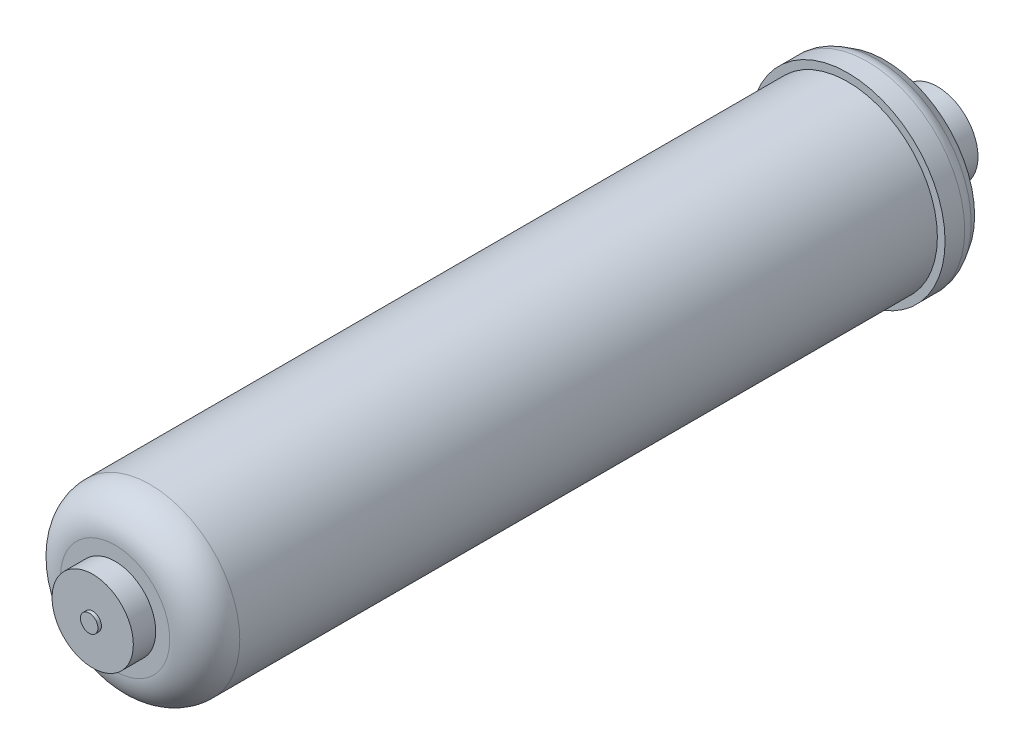
from build123d import *

# Parameters (mm, degrees)
FILLET1_R = 12.7
FILLET2_R = 6.35


with BuildPart() as part:
    # Sketch1 → Revolve1 (revolve)
    with BuildSketch(Plane(origin=(0, 0, 0), x_dir=(0, 0, -1), z_dir=(1, 0, 0))):
        Polygon((0, 0), (0, 3.175), (1.27, 3.175), (1.27, 14.732), (9.398, 14.732), (9.398, 32.512), (275.082, 32.512), (275.082, 35.306), (283.972, 35.306), (288.544, 32.555084127), (299.466, 14.732), (307.594, 14.732), (307.594, 3.175), (308.864, 3.175), (308.864, 0), align=None)
    revolve(axis=Axis((0, 0, 0), (0, 0, -1)))

    # Fillet1
    fillet1_edges = [part.edges().sort_by_distance(p)[0] for p in [
        (0, -32.512, -9.398),
    ]]
    fillet(fillet1_edges, radius=FILLET1_R)

    # Fillet2
    fillet2_edges = [part.edges().sort_by_distance(p)[0] for p in [
        (0, -35.306, -283.972),
    ]]
    fillet(fillet2_edges, radius=FILLET2_R)


solid = part.part
